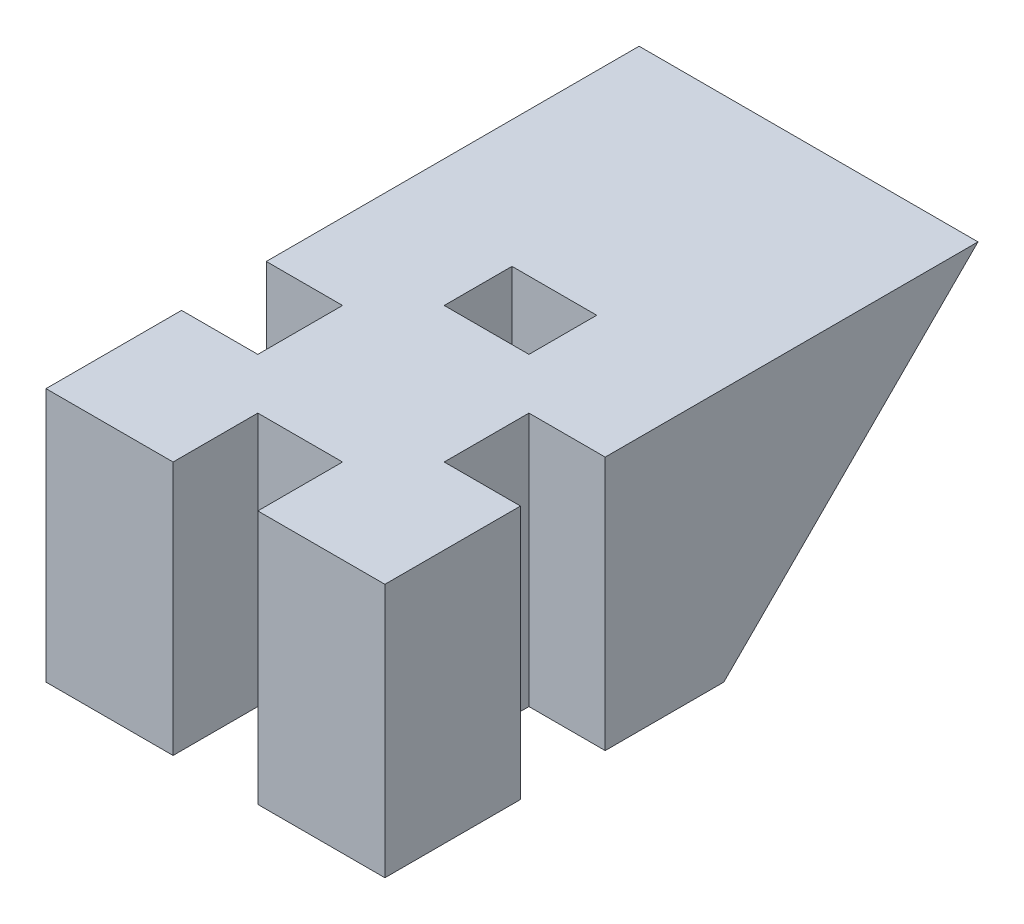
from build123d import *

# Parameters (mm, degrees)
SKETCH2_W           = 20
SKETCH2_H           = 20
BOSS_EXTRUDE2_DEPTH = 40
SKETCH4_W           = 5
SKETCH4_H           = 10
CUT_EXTRUDE1_DEPTH  = 41
CIRPATTERN1_COUNT   = 4
SKETCH10_W          = 20
SKETCH10_H          = 15
BOSS_EXTRUDE4_DEPTH = 15
CUT_EXTRUDE3_DEPTH  = 21
SKETCH13_W          = 20
SKETCH13_H          = 25
CUT_EXTRUDE4_DEPTH  = 21


with BuildPart() as part:
    # Sketch2 → Boss-Extrude2 (new body)
    with BuildSketch(Plane(origin=(0, 0, 0), x_dir=(1, 0, 0), z_dir=(0, 1, 0))):
        Rectangle(SKETCH2_W, SKETCH2_H)
    extrude(amount=BOSS_EXTRUDE2_DEPTH)

    # Sketch4 → Cut-Extrude1 (cut, through all)
    with BuildSketch(Plane.XZ):
        with Locations((0, 10)):
            Rectangle(SKETCH4_W, SKETCH4_H)
    cut_extrude1 = extrude(amount=-CUT_EXTRUDE1_DEPTH, mode=Mode.SUBTRACT)

    # CirPattern1: Cut-Extrude1 ×4 about axis
    cirpattern1_axis = Axis((0, 0, -0.5), (0, 1, 0))
    for i in range(1, CIRPATTERN1_COUNT):
        add(cut_extrude1.rotate(cirpattern1_axis, i * 360 / CIRPATTERN1_COUNT), mode=Mode.SUBTRACT)

    # Sketch10 → Boss-Extrude4 (add)
    with BuildSketch(Plane(origin=(0, 0, -10), x_dir=(-1, 0, 0), z_dir=(0, 0, -1))):
        with Locations((0, 32.5)):
            Rectangle(SKETCH10_W, SKETCH10_H)
    extrude(amount=BOSS_EXTRUDE4_DEPTH)

    # Sketch12 → Cut-Extrude3 (cut, through all)
    with BuildSketch(Plane.ZY.offset(10)):
        Polygon((-25, 40), (-10, 25), (-25, 25), align=None)
    extrude(amount=-CUT_EXTRUDE3_DEPTH, mode=Mode.SUBTRACT)

    # Sketch13 → Cut-Extrude4 (cut, through all)
    with BuildSketch(Plane.ZY.offset(10)):
        with Locations((0, 12.5)):
            Rectangle(SKETCH13_W, SKETCH13_H)
    extrude(amount=-CUT_EXTRUDE4_DEPTH, mode=Mode.SUBTRACT)


solid = part.part
